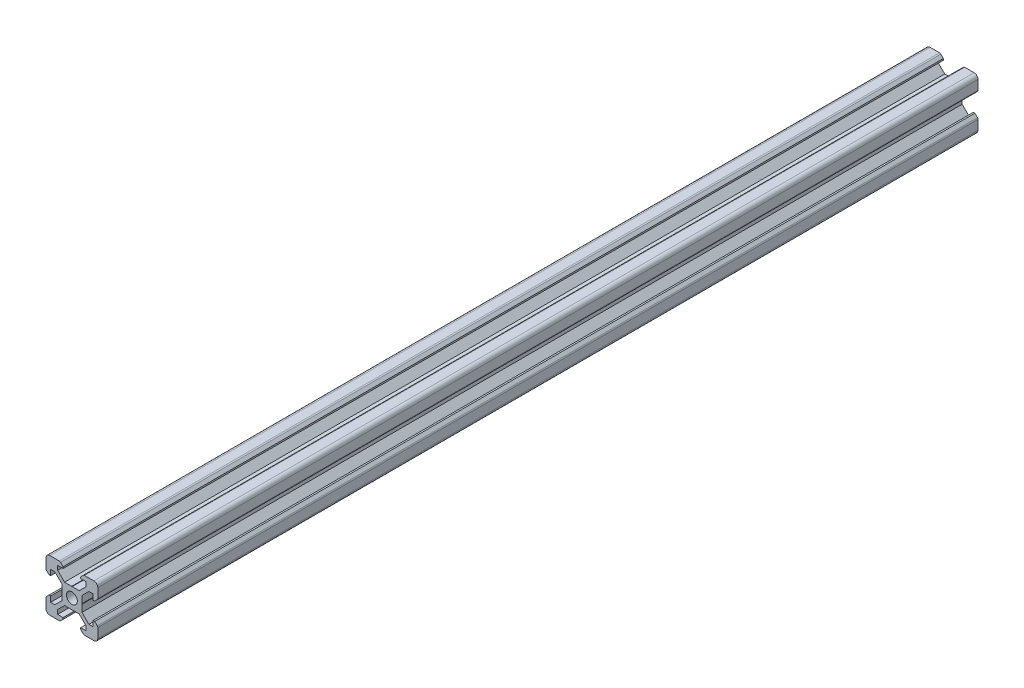
from build123d import *

# Parameters (mm, degrees)
SKETCH1_R           = 2.1
BOSS_EXTRUDE1_DEPTH = 340


with BuildPart() as part:
    # Sketch1 → Boss-Extrude1 (new body)
    with BuildSketch(Plane.XY):
        with BuildLine():
            Line((-8.5, 10), (-4.862792737, 10))
            ThreePointArc((-4.862792737, 10), (-4.598292737, 9.947387679), (-4.374060464, 9.797560464))
            Line((-4.374060464, 9.797560464), (-3.3865, 8.81))
            Line((-3.3865, 8.81), (-3.3865, 8.2))
            Line((-3.3865, 8.2), (-5.5, 8.2))
            Line((-5.5, 8.2), (-5.5, 6.561))
            Line((-5.5, 6.561), (-2.8395, 3.9005))
            Line((-2.8395, 3.9005), (-0.1, 3.9005))
            Line((-0.1, 3.9005), (0, 3.8005))
            Line((0, 3.8005), (0.1, 3.9005))
            Line((0.1, 3.9005), (2.8395, 3.9005))
            Line((2.8395, 3.9005), (5.5, 6.561))
            Line((5.5, 6.561), (5.5, 8.2))
            Line((5.5, 8.2), (3.3865, 8.2))
            Line((3.3865, 8.2), (3.3865, 8.81))
            Line((3.3865, 8.81), (4.374060464, 9.797560464))
            ThreePointArc((4.374060464, 9.797560464), (4.598292737, 9.947387679), (4.862792737, 10))
            Line((4.862792737, 10), (8.5, 10))
            ThreePointArc((8.5, 10), (9.560660172, 9.560660172), (10, 8.5))
            Line((10, 8.5), (10, 4.862792737))
            ThreePointArc((10, 4.862792737), (9.947387679, 4.598292737), (9.797560464, 4.374060464))
            Line((9.797560464, 4.374060464), (8.81, 3.3865))
            Line((8.81, 3.3865), (8.2, 3.3865))
            Line((8.2, 3.3865), (8.2, 5.5))
            Line((8.2, 5.5), (6.561, 5.5))
            Line((6.561, 5.5), (3.9005, 2.8395))
            Line((3.9005, 2.8395), (3.9005, 0.1))
            Line((3.9005, 0.1), (3.8005, 0))
            Line((3.8005, 0), (3.9005, -0.1))
            Line((3.9005, -0.1), (3.9005, -2.8395))
            Line((3.9005, -2.8395), (6.561, -5.5))
            Line((6.561, -5.5), (8.2, -5.5))
            Line((8.2, -5.5), (8.2, -3.3865))
            Line((8.2, -3.3865), (8.81, -3.3865))
            Line((8.81, -3.3865), (9.797560464, -4.374060464))
            ThreePointArc((9.797560464, -4.374060464), (9.947387679, -4.598292737), (10, -4.862792737))
            Line((10, -4.862792737), (10, -8.5))
            ThreePointArc((10, -8.5), (9.560660172, -9.560660172), (8.5, -10))
            Line((8.5, -10), (4.862792737, -10))
            ThreePointArc((4.862792737, -10), (4.598292737, -9.947387679), (4.374060464, -9.797560464))
            Line((4.374060464, -9.797560464), (3.3865, -8.81))
            Line((3.3865, -8.81), (3.3865, -8.2))
            Line((3.3865, -8.2), (5.5, -8.2))
            Line((5.5, -8.2), (5.5, -6.561))
            Line((5.5, -6.561), (2.8395, -3.9005))
            Line((2.8395, -3.9005), (0.1, -3.9005))
            Line((0.1, -3.9005), (0, -3.8005))
            Line((0, -3.8005), (-0.1, -3.9005))
            Line((-0.1, -3.9005), (-2.8395, -3.9005))
            Line((-2.8395, -3.9005), (-5.5, -6.561))
            Line((-5.5, -6.561), (-5.5, -8.2))
            Line((-5.5, -8.2), (-3.3865, -8.2))
            Line((-3.3865, -8.2), (-3.3865, -8.81))
            Line((-3.3865, -8.81), (-4.374060464, -9.797560464))
            ThreePointArc((-4.374060464, -9.797560464), (-4.598292737, -9.947387679), (-4.862792737, -10))
            Line((-4.862792737, -10), (-8.5, -10))
            ThreePointArc((-8.5, -10), (-9.560660172, -9.560660172), (-10, -8.5))
            Line((-10, -8.5), (-10, -4.862792737))
            ThreePointArc((-10, -4.862792737), (-9.947387679, -4.598292737), (-9.797560464, -4.374060464))
            Line((-9.797560464, -4.374060464), (-8.81, -3.3865))
            Line((-8.81, -3.3865), (-8.2, -3.3865))
            Line((-8.2, -3.3865), (-8.2, -5.5))
            Line((-8.2, -5.5), (-6.561, -5.5))
            Line((-6.561, -5.5), (-3.9005, -2.8395))
            Line((-3.9005, -2.8395), (-3.9005, -0.1))
            Line((-3.9005, -0.1), (-3.8005, 0))
            Line((-3.8005, 0), (-3.9005, 0.1))
            Line((-3.9005, 0.1), (-3.9005, 2.8395))
            Line((-3.9005, 2.8395), (-6.561, 5.5))
            Line((-6.561, 5.5), (-8.2, 5.5))
            Line((-8.2, 5.5), (-8.2, 3.3865))
            Line((-8.2, 3.3865), (-8.81, 3.3865))
            Line((-8.81, 3.3865), (-9.797560464, 4.374060464))
            ThreePointArc((-9.797560464, 4.374060464), (-9.947387679, 4.598292737), (-10, 4.862792737))
            Line((-10, 4.862792737), (-10, 8.5))
            ThreePointArc((-10, 8.5), (-9.560660172, 9.560660172), (-8.5, 10))
        make_face()
        Circle(SKETCH1_R, mode=Mode.SUBTRACT)
    extrude(amount=BOSS_EXTRUDE1_DEPTH)


solid = part.part
